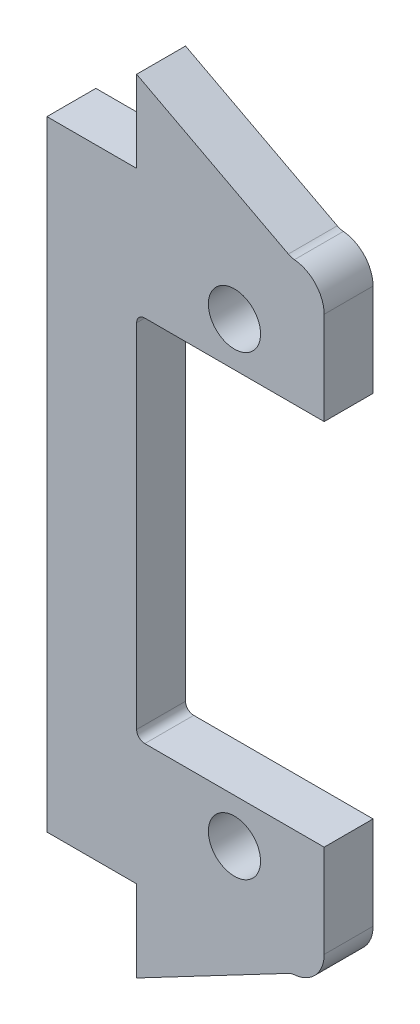
from build123d import *

# Parameters (mm, degrees)
SKETCH_1_R      = 1.6
EXTRUDE_1_DEPTH = 3
FILLET_1_R      = 0.5
FILLET_2_R      = 2
EXTRUDE_2_DEPTH = 3
FILLET_3_R      = 1


with BuildPart() as part:
    # ｽｹｯﾁ1 → ﾎﾞｽ - 押し出し1 (new body)
    with BuildSketch(Plane.XY):
        Polygon((0, -19), (0, 19), (17, 19), (17, 11.3), (5.5, 11.3), (5.5, -11.3), (17, -11.3), (17, -19), align=None)
        with Locations((11.5, 14)):
            Circle(SKETCH_1_R, mode=Mode.SUBTRACT)
        with Locations((11.5, -14)):
            Circle(SKETCH_1_R, mode=Mode.SUBTRACT)
    extrude(amount=EXTRUDE_1_DEPTH)

    # ﾌｨﾚｯﾄ1
    fillet_1_edges = [part.edges().sort_by_distance(p)[0] for p in [
        (5.5, 11.3, 1.5),
        (5.5, -11.3, 1.5),
    ]]
    fillet(fillet_1_edges, radius=FILLET_1_R)

    # ﾌｨﾚｯﾄ2
    fillet_2_edges = [part.edges().sort_by_distance(p)[0] for p in [
        (17, 19, 1.5),
        (17, -19, 1.5),
    ]]
    fillet(fillet_2_edges, radius=FILLET_2_R)

    # ｽｹｯﾁ2 → ﾎﾞｽ - 押し出し2 (add)
    with BuildSketch(Plane.XY.offset(3)):
        Polygon((5.5, 19), (5.5, 24), (15, 19), align=None)
        Polygon((5.5, -19), (5.5, -24), (15, -19), align=None)
    extrude(amount=-EXTRUDE_2_DEPTH)

    # ﾌｨﾚｯﾄ3
    fillet_3_edges = [part.edges().sort_by_distance(p)[0] for p in [
        (15, 19, 1.5),
        (15, -19, 1.5),
    ]]
    fillet(fillet_3_edges, radius=FILLET_3_R)


solid = part.part
